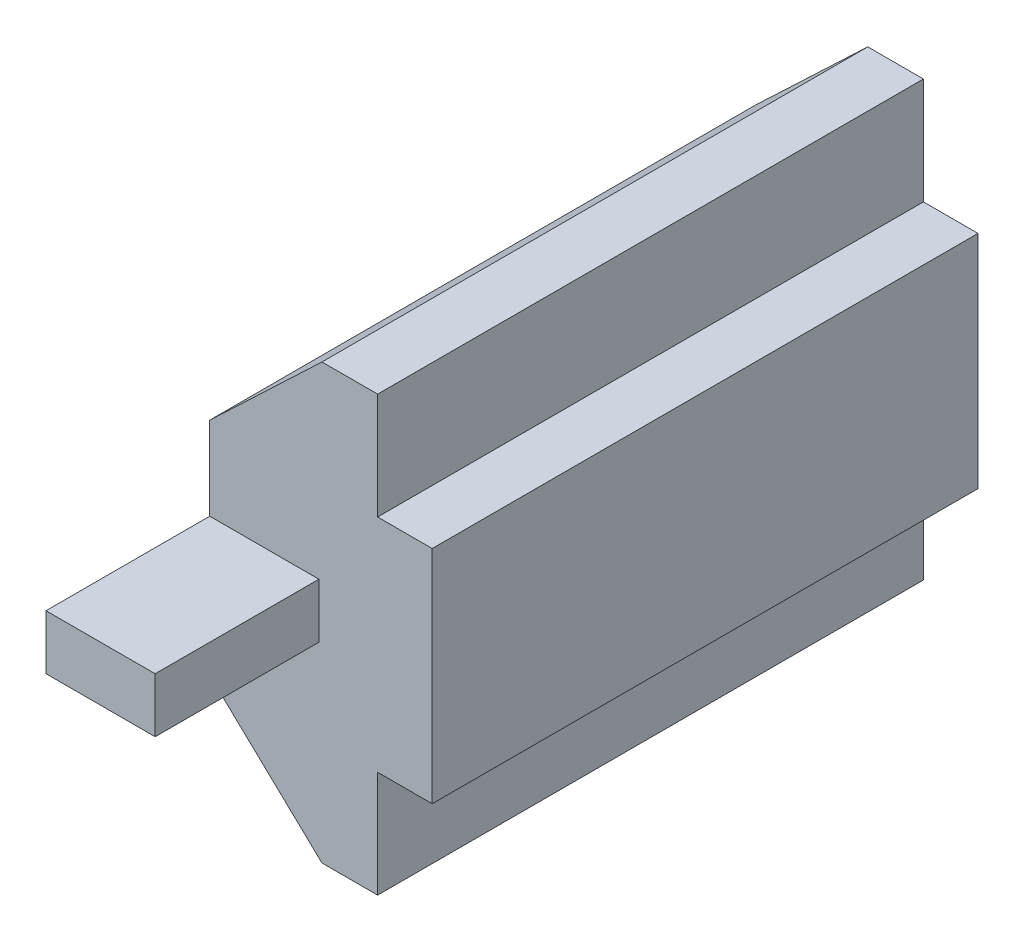
from build123d import *

# Parameters (mm, degrees)
SKETCH2_W           = 2
SKETCH2_H           = 8.1
BOSS_EXTRUDE1_DEPTH = 20
SKETCH3_W           = 4
SKETCH3_H           = 2
BOSS_EXTRUDE2_DEPTH = 6


with BuildPart() as part:
    # Sketch2 → Boss-Extrude1 (new body)
    with BuildSketch(Plane.XY):
        Polygon((-2.04, 7.95), (0, 7.95), (0, -7.95), (-2.04, -7.95), (-6.152414984, -4.048), (-6.152414984, 4.048), align=None)
        with Locations((1, 0)):
            Rectangle(SKETCH2_W, SKETCH2_H)
    extrude(amount=BOSS_EXTRUDE1_DEPTH)

    # Sketch3 → Boss-Extrude2 (add)
    with BuildSketch(Plane.XY.offset(20)):
        with Locations((-4.152414984, 0)):
            Rectangle(SKETCH3_W, SKETCH3_H)
    extrude(amount=BOSS_EXTRUDE2_DEPTH)


solid = part.part
